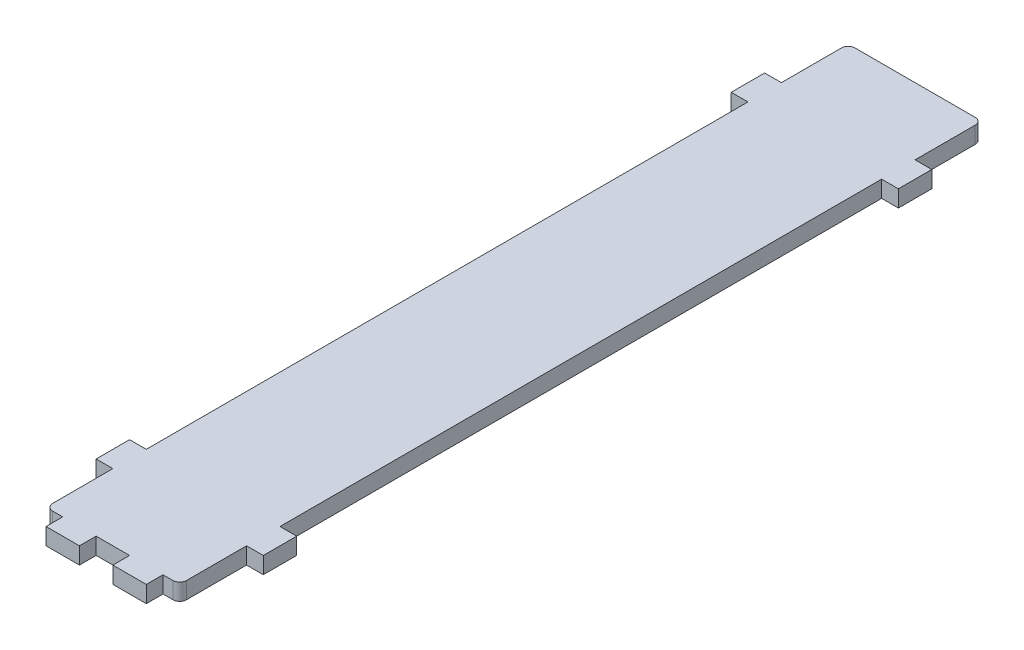
from build123d import *

# Parameters (mm, degrees)
SIDE_PLATE_DEPTH = 6.35
FILLET1_R        = 2.54


with BuildPart() as part:
    # Sketch1 → Side Plate (new body)
    with BuildSketch(Plane(origin=(0, 0, 0), x_dir=(1, 0, 0), z_dir=(0, 1, 0))):
        Polygon((0, 0), (6.35, 0), (6.35, -6.35), (19.05, -6.35), (19.05, 0), (31.75, 0), (31.75, -6.35), (44.45, -6.35), (44.45, 0), (50.8, 0), (50.8, 25.4), (57.15, 25.4), (57.15, 38.1), (50.8, 38.1), (50.8, 266.7), (57.15, 266.7), (57.15, 279.4), (50.8, 279.4), (50.8, 304.8), (0, 304.8), (0, 279.4), (-6.35, 279.4), (-6.35, 266.7), (0, 266.7), (0, 38.1), (-6.35, 38.1), (-6.35, 25.4), (0, 25.4), align=None)
    extrude(amount=SIDE_PLATE_DEPTH)

    # Fillet1
    fillet1_edges = [part.edges().sort_by_distance(p)[0] for p in [
        (0, 3.175, -304.8),
        (50.8, 3.175, -304.8),
        (50.8, 3.175, 0),
        (0, 3.175, 0),
    ]]
    fillet(fillet1_edges, radius=FILLET1_R)


solid = part.part
